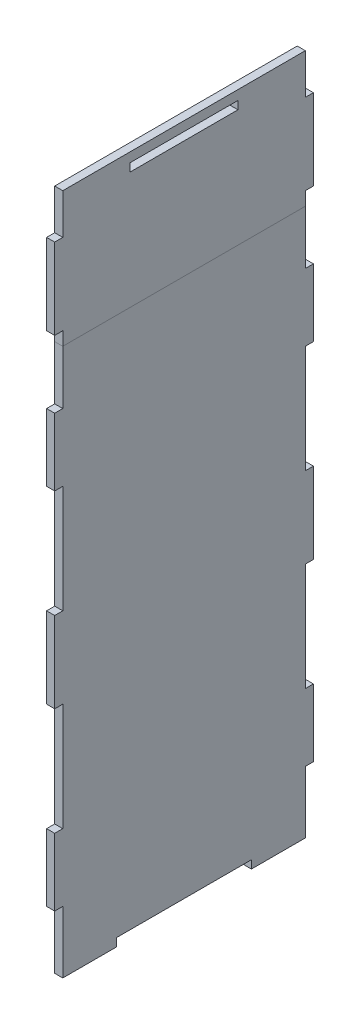
from build123d import *

# Parameters (mm, degrees)
SKETCH1_W           = 90
SKETCH1_H           = 200
BOSS_EXTRUDE1_DEPTH = 3
SKETCH4_W           = 3
SKETCH4_H           = 25
SKETCH4_H_2         = 30
BOSS_EXTRUDE3_DEPTH = 3
SKETCH5_W           = 20
SKETCH5_H           = 3
BOSS_EXTRUDE4_DEPTH = 3
SKETCH6_W           = 90
SKETCH6_H           = 50
BOSS_EXTRUDE5_DEPTH = 3
SKETCH7_W           = 40
SKETCH7_H           = 3
CUT_EXTRUDE2_DEPTH  = 3
SKETCH8_W           = 3
SKETCH8_H           = 30
BOSS_EXTRUDE6_DEPTH = 3


with BuildPart() as part:
    # Sketch1 → Boss-Extrude1 (new body)
    with BuildSketch(Plane(origin=(0, 0, 0), x_dir=(0, 0, -1), z_dir=(1, 0, 0))):
        with Locations((45, 100)):
            Rectangle(SKETCH1_W, SKETCH1_H)
    extrude(amount=BOSS_EXTRUDE1_DEPTH)

    # Sketch4 → Boss-Extrude3 (add, through all)
    with BuildSketch(Plane(origin=(3, 0, 0), x_dir=(0, 0, -1), z_dir=(1, 0, 0))):
        with Locations((-1.5, 167.5)):
            Rectangle(SKETCH4_W, SKETCH4_H)
        with Locations((-1.5, 100)):
            Rectangle(SKETCH4_W, SKETCH4_H_2)
        with Locations((-1.5, 32.5)):
            Rectangle(SKETCH4_W, SKETCH4_H)
        with Locations((91.5, 32.5)):
            Rectangle(SKETCH4_W, SKETCH4_H)
        with Locations((91.5, 100)):
            Rectangle(SKETCH4_W, SKETCH4_H_2)
        with Locations((91.5, 167.5)):
            Rectangle(SKETCH4_W, SKETCH4_H)
    extrude(amount=-BOSS_EXTRUDE3_DEPTH)

    # Sketch5 → Boss-Extrude4 (add, through all)
    with BuildSketch(Plane(origin=(3, 0, 0), x_dir=(0, 0, -1), z_dir=(1, 0, 0))):
        with Locations((10, -1.5)):
            Rectangle(SKETCH5_W, SKETCH5_H)
        with Locations((80, -1.5)):
            Rectangle(SKETCH5_W, SKETCH5_H)
    extrude(amount=-BOSS_EXTRUDE4_DEPTH)


with BuildPart() as body_2:
    # Sketch6 → Boss-Extrude5 (new body)
    with BuildSketch(Plane(origin=(3, 0, 0), x_dir=(0, 0, -1), z_dir=(1, 0, 0))):
        with Locations((45, 225)):
            Rectangle(SKETCH6_W, SKETCH6_H)
    extrude(amount=-BOSS_EXTRUDE5_DEPTH)

    # Sketch7 → Cut-Extrude2 (cut)
    with BuildSketch(Plane(origin=(3, 0, 0), x_dir=(0, 0, -1), z_dir=(1, 0, 0))):
        with Locations((45, 245)):
            Rectangle(SKETCH7_W, SKETCH7_H)
    extrude(amount=-CUT_EXTRUDE2_DEPTH, mode=Mode.SUBTRACT)

    # Sketch8 → Boss-Extrude6 (add)
    with BuildSketch(Plane(origin=(3, 0, 0), x_dir=(0, 0, -1), z_dir=(1, 0, 0))):
        with Locations((-1.5, 220)):
            Rectangle(SKETCH8_W, SKETCH8_H)
        with Locations((91.5, 220)):
            Rectangle(SKETCH8_W, SKETCH8_H)
    extrude(amount=-BOSS_EXTRUDE6_DEPTH)


solid = Compound([part.part, body_2.part])
